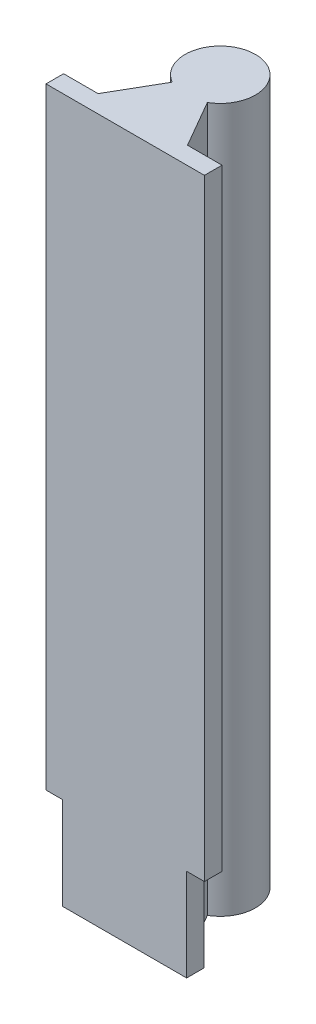
from build123d import *

# Parameters (mm, degrees)
BOSS_EXTRUDE1_DEPTH = 200
SKETCH2_W           = 9.23188111
SKETCH2_H           = 28.936228776
SKETCH2_W_2         = 10.092838874
CUT_EXTRUDE1_DEPTH  = 6


with BuildPart() as part:
    # Sketch1 → Boss-Extrude1 (new body)
    with BuildSketch(Plane(origin=(0, 0, 0), x_dir=(1, 0, 0), z_dir=(0, 1, 0))):
        with BuildLine():
            Line((22.5, -2.5), (-22.5, -2.5))
            Line((-22.5, -2.5), (-22.5, 2.5))
            Line((-22.5, 2.5), (-12.701705922, 2.5))
            Line((-12.701705922, 2.5), (-5, 15.839745962))
            ThreePointArc((-5, 15.839745962), (0, 34.5), (5, 15.839745962))
            Line((5, 15.839745962), (12.701705922, 2.5))
            Line((12.701705922, 2.5), (22.5, 2.5))
            Line((22.5, 2.5), (22.5, -2.5))
        make_face()
    extrude(amount=BOSS_EXTRUDE1_DEPTH)

    # Sketch2 → Cut-Extrude1 (cut, through all)
    with BuildSketch(Plane(origin=(0, 0, -2.5), x_dir=(-1, 0, 0), z_dir=(0, 0, -1))):
        with Locations((22.5, 11.786741845)):
            Rectangle(SKETCH2_W, SKETCH2_H)
        with Locations((-22.5, 11.786741845)):
            Rectangle(SKETCH2_W_2, SKETCH2_H)
    extrude(amount=-CUT_EXTRUDE1_DEPTH, mode=Mode.SUBTRACT)


solid = part.part
